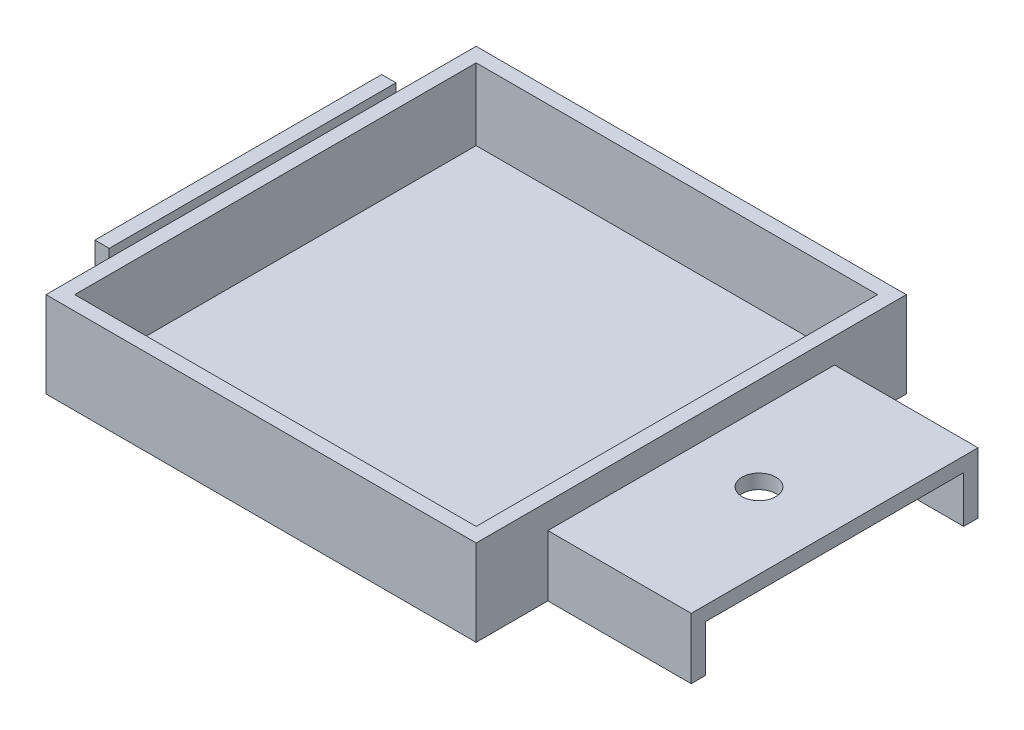
from build123d import *

# Parameters (mm, degrees)
SKETCH1_W           = 76.2
SKETCH1_H           = 76.2
BOSS_EXTRUDE1_DEPTH = 2.54
SKETCH2_W           = 76.2
SKETCH2_H           = 76.2
SKETCH2_W_2         = 71.12
SKETCH2_H_2         = 71.12
BOSS_EXTRUDE2_DEPTH = 12.7
SKETCH3_W           = 50.8
SKETCH3_H           = 2.54
BOSS_EXTRUDE3_DEPTH = 25.4
SKETCH5_R           = 3
CUT_EXTRUDE2_DEPTH  = 11.795
SKETCH6_W           = 25.4
SKETCH6_H           = 2.54
BOSS_EXTRUDE4_DEPTH = 8.255
SKETCH9_W           = 50.8
SKETCH9_H           = 2.54
BOSS_EXTRUDE5_DEPTH = 1.5
SKETCH10_W          = 50.8
SKETCH10_H          = 15.24
BOSS_EXTRUDE6_DEPTH = 2.54


with BuildPart() as part:
    # Sketch1 → Boss-Extrude1 (new body)
    with BuildSketch(Plane(origin=(0, 0, 0), x_dir=(1, 0, 0), z_dir=(0, 1, 0))):
        with Locations((38.1, 38.1)):
            Rectangle(SKETCH1_W, SKETCH1_H)
    extrude(amount=BOSS_EXTRUDE1_DEPTH)

    # Sketch2 → Boss-Extrude2 (add)
    with BuildSketch(Plane(origin=(0, 2.54, 0), x_dir=(1, 0, 0), z_dir=(0, 1, 0))):
        with Locations((38.1, 38.1)):
            Rectangle(SKETCH2_W, SKETCH2_H)
        with Locations((38.1, 38.1)):
            Rectangle(SKETCH2_W_2, SKETCH2_H_2, mode=Mode.SUBTRACT)
    extrude(amount=BOSS_EXTRUDE2_DEPTH)

    # Sketch3 → Boss-Extrude3 (add)
    with BuildSketch(Plane(origin=(76.2, 0, 0), x_dir=(0, 0, -1), z_dir=(1, 0, 0))):
        with Locations((38.1, 9.525)):
            Rectangle(SKETCH3_W, SKETCH3_H)
    extrude(amount=BOSS_EXTRUDE3_DEPTH)

    # Sketch5 → Cut-Extrude2 (cut, through all)
    with BuildSketch(Plane(origin=(0, 10.795, 0), x_dir=(1, 0, 0), z_dir=(0, 1, 0))):
        with Locations((88.2, 38.1)):
            Circle(SKETCH5_R)
    extrude(amount=-CUT_EXTRUDE2_DEPTH, mode=Mode.SUBTRACT)

    # Sketch6 → Boss-Extrude4 (add)
    with BuildSketch(Plane.XZ.offset(-8.255)):
        with Locations((88.9, -13.97)):
            Rectangle(SKETCH6_W, SKETCH6_H)
        with Locations((88.9, -62.23)):
            Rectangle(SKETCH6_W, SKETCH6_H)
    extrude(amount=BOSS_EXTRUDE4_DEPTH)

    # Sketch9 → Boss-Extrude5 (add)
    with BuildSketch(Plane.ZY):
        with Locations((-38.1, 1.27)):
            Rectangle(SKETCH9_W, SKETCH9_H)
    extrude(amount=BOSS_EXTRUDE5_DEPTH)

    # Sketch10 → Boss-Extrude6 (add)
    with BuildSketch(Plane.ZY.offset(1.5)):
        with Locations((-38.1, 7.62)):
            Rectangle(SKETCH10_W, SKETCH10_H)
    extrude(amount=BOSS_EXTRUDE6_DEPTH)


solid = part.part
